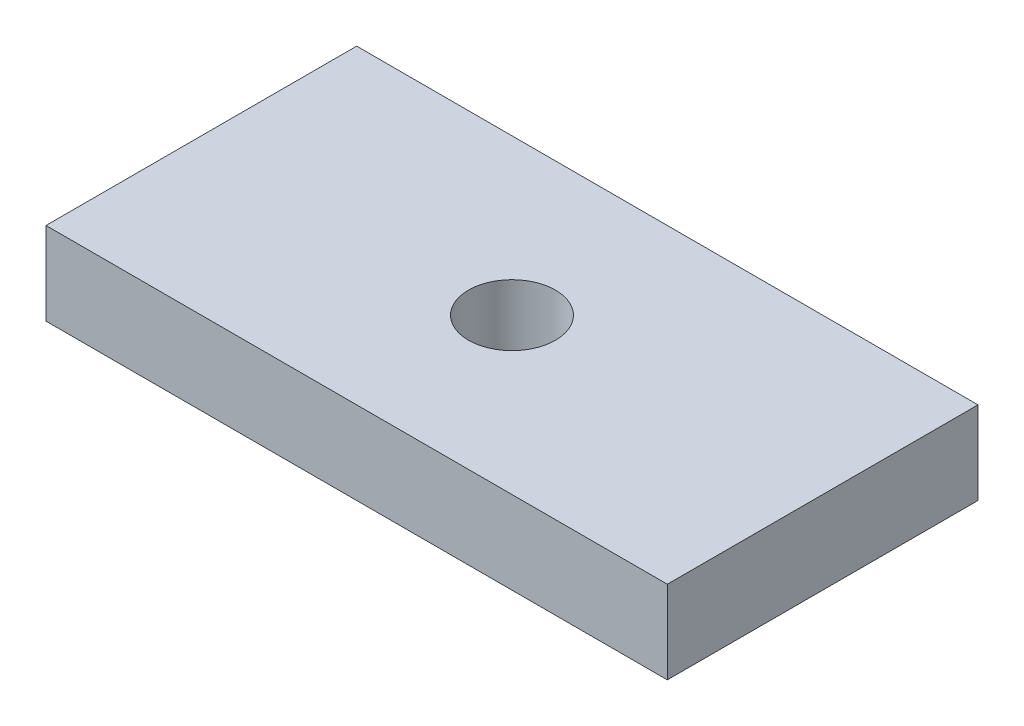
from build123d import *

# Parameters (mm, degrees)
SKIZZE1_W                       = 30
SKIZZE1_H                       = 15
SKIZZE1_R                       = 2.1
AUFSATZ_LINEAR_AUSTRAGEN1_DEPTH = 2


with BuildPart() as part:
    # Skizze1 → Aufsatz-Linear austragen1 (new body, symmetric)
    with BuildSketch(Plane(origin=(0, 0, 0), x_dir=(1, 0, 0), z_dir=(0, 1, 0))):
        Rectangle(SKIZZE1_W, SKIZZE1_H)
        Circle(SKIZZE1_R, mode=Mode.SUBTRACT)
    extrude(amount=AUFSATZ_LINEAR_AUSTRAGEN1_DEPTH, both=True)


solid = part.part
